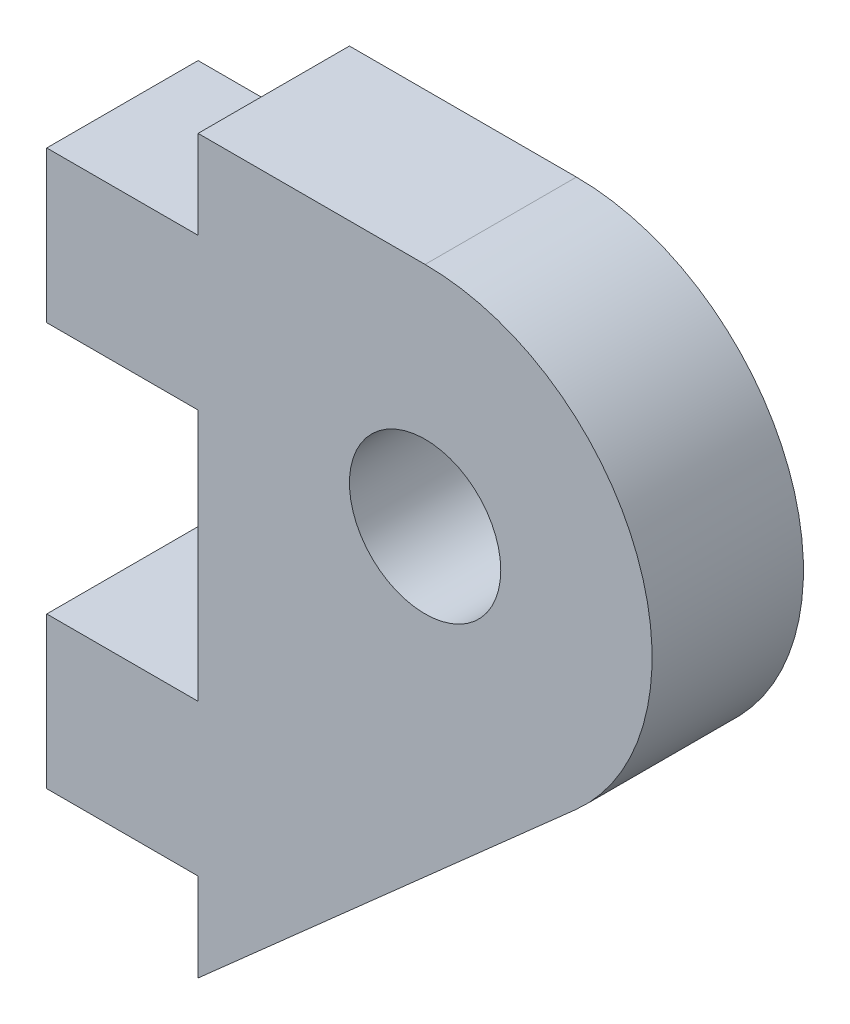
from build123d import *

# Parameters (mm, degrees)
SKETCH1_R           = 1.5
BOSS_EXTRUDE1_DEPTH = 1.5
SKETCH2_W           = 3
SKETCH2_H           = 3
BOSS_EXTRUDE2_DEPTH = 3


with BuildPart() as part:
    # Sketch1 → Boss-Extrude1 (new body, symmetric)
    with BuildSketch(Plane.XY):
        with BuildLine():
            Line((0, 0), (0, 10))
            Line((0, 10), (0, 14.5))
            Line((0, 14.5), (4.5, 14.5))
            ThreePointArc((4.5, 14.5), (8.707488868, 11.595944054), (7.484407484, 6.632016632))
            Line((7.484407484, 6.632016632), (0, 0))
        make_face()
        with Locations((4.5, 10)):
            Circle(SKETCH1_R, mode=Mode.SUBTRACT)
    extrude(amount=BOSS_EXTRUDE1_DEPTH, both=True)

    # Sketch2 → Boss-Extrude2 (add)
    with BuildSketch(Plane.ZY):
        with Locations((0, 11.25)):
            Rectangle(SKETCH2_W, SKETCH2_H)
        with Locations((0, 3.25)):
            Rectangle(SKETCH2_W, SKETCH2_H)
    extrude(amount=BOSS_EXTRUDE2_DEPTH)


solid = part.part
